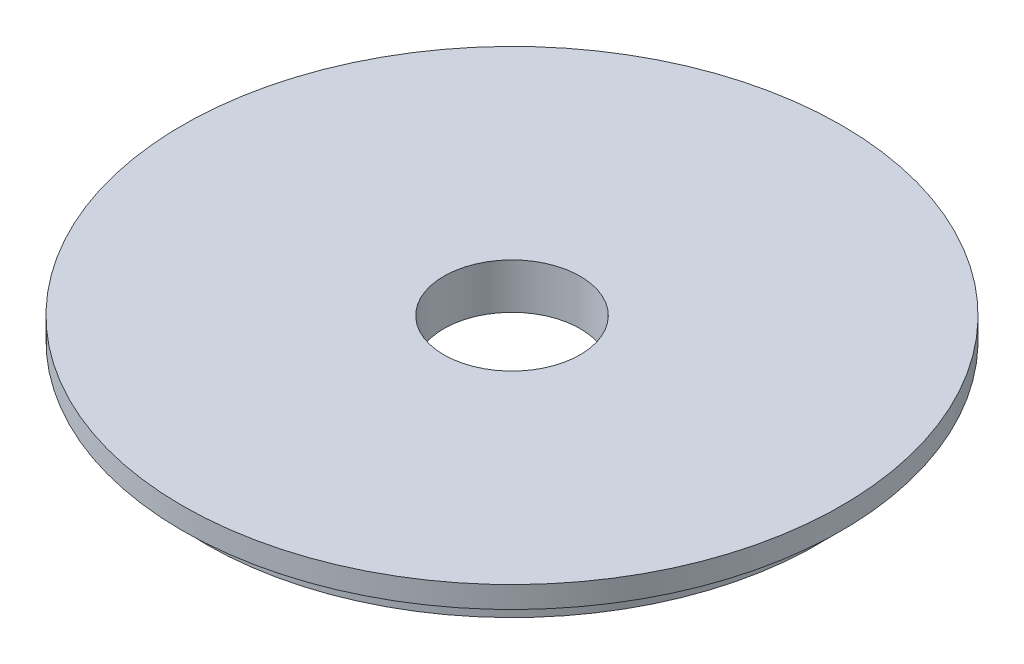
from build123d import *


with BuildPart() as part:
    # Sketch1 → Revolve1 (revolve)
    with BuildSketch(Plane.XY):
        Polygon((-9.525, 0), (-46.0756, 0), (-46.0756, -3.0226), (-42.7482, -3.0226), (-42.7482, -6.35), (-9.525, -6.35), align=None)
    revolve(axis=Axis((0, 0, 0), (0, -1, 0)))


solid = part.part
